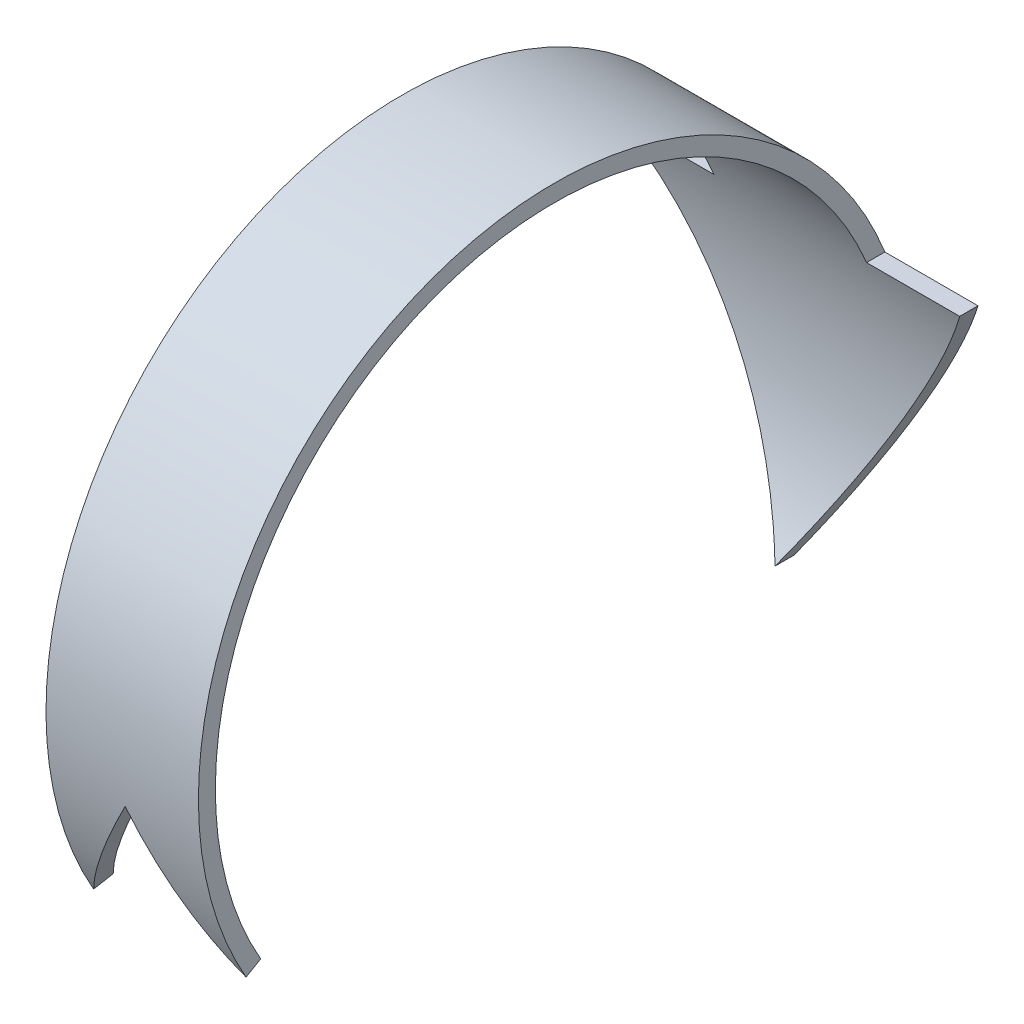
from build123d import *

# Parameters (mm, degrees)
CIRCULARBAND_W               = 50
CIRCULARBAND_H               = 2.5
BASE_REVOLVE_ANGLE           = 120
BASE_REVOLVE_OTHER_WAY_ANGLE = 120
SKETCH9_OUTSIDE_W            = 80.09
SKETCH9_OUTSIDE_H            = 108.84
HEAD1_DEPTH                  = 53.5
SKETCH10_OUTSIDE_W           = 80.09
SKETCH10_OUTSIDE_H           = 108.84
TAIL1_DEPTH                  = 53.5


with BuildPart() as part:
    # circularband → Base-Revolve (revolve)
    with BuildSketch(Plane.XY):
        with Locations((0, 51.25)):
            Rectangle(CIRCULARBAND_W, CIRCULARBAND_H)
    revolve(axis=Axis((0, 0, 0), (1, 0, 0)), revolution_arc=BASE_REVOLVE_ANGLE)

    # circularband → Base-Revolve other way (revolve)
    with BuildSketch(Plane.XY):
        with Locations((0, 51.25)):
            Rectangle(CIRCULARBAND_W, CIRCULARBAND_H)
    revolve(axis=Axis((0, 0, 0), (-1, 0, 0)), revolution_arc=BASE_REVOLVE_OTHER_WAY_ANGLE)

    # Sketch9 outside → head1 (cut, through all)
    with BuildSketch(Plane.XY):
        with Locations((0, 13.125)):
            Rectangle(SKETCH9_OUTSIDE_W, SKETCH9_OUTSIDE_H)
        Polygon((-11.25, 52.5), (11.25, 52.5), (11.25, 19.301270189), (25, 19.301270189), (0, -24), (-25, 19.301270189), (-11.25, 19.301270189), align=None, mode=Mode.SUBTRACT)
    extrude(amount=-HEAD1_DEPTH, mode=Mode.SUBTRACT)

    # Sketch10 outside → tail1 (cut, through all)
    with BuildSketch(Plane.XY):
        with Locations((0, 13.125)):
            Rectangle(SKETCH10_OUTSIDE_W, SKETCH10_OUTSIDE_H)
        Polygon((0, -6.764428415), (11.25, -26.25), (11.25, 52.5), (-11.25, 52.5), (-11.25, -26.25), align=None, mode=Mode.SUBTRACT)
    extrude(amount=TAIL1_DEPTH, mode=Mode.SUBTRACT)


solid = part.part
